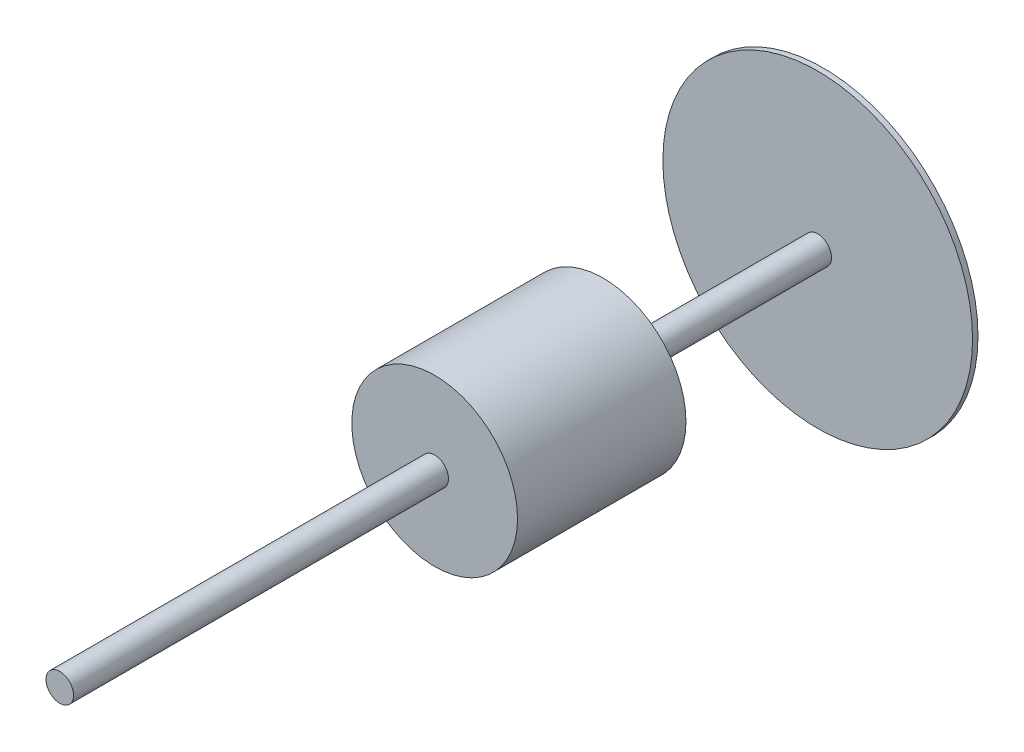
from build123d import *

# Parameters (mm, degrees)
SKETCH1_R                = 50.8
BOSS_EXTRUDE1_DEPTH      = 2130
BOSS_EXTRUDE1_DEPTH_BACK = 680
SKETCH2_R                = 570
BOSS_EXTRUDE2_DEPTH      = 20
BOSS_EXTRUDE3_START      = -1380
SKETCH7_R                = 305
BOSS_EXTRUDE3_DEPTH      = 620
SKETCH8_R                = 225
BOSS_EXTRUDE4_DEPTH      = 50


with BuildPart() as part:
    # Sketch1 → Boss-Extrude1 (new body, two sides)
    with BuildSketch(Plane.XY) as boss_extrude1_sk:
        Circle(SKETCH1_R)
    extrude(amount=BOSS_EXTRUDE1_DEPTH)
    extrude(boss_extrude1_sk.sketch, amount=-BOSS_EXTRUDE1_DEPTH_BACK)

    # Sketch2 → Boss-Extrude2 (add)
    with BuildSketch(Plane.XY.offset(-680)):
        Circle(SKETCH2_R)
    extrude(amount=BOSS_EXTRUDE2_DEPTH)

    # Sketch7 → Boss-Extrude3 (add)
    with BuildSketch(Plane.XY.offset(2130).offset(BOSS_EXTRUDE3_START)):
        Circle(SKETCH7_R)
    extrude(amount=-BOSS_EXTRUDE3_DEPTH)

    # Sketch8 → Boss-Extrude4 (add)
    with BuildSketch(Plane(origin=(0, 0, 130), x_dir=(-1, 0, 0), z_dir=(0, 0, -1))):
        Circle(SKETCH8_R)
    extrude(amount=BOSS_EXTRUDE4_DEPTH)


solid = part.part
